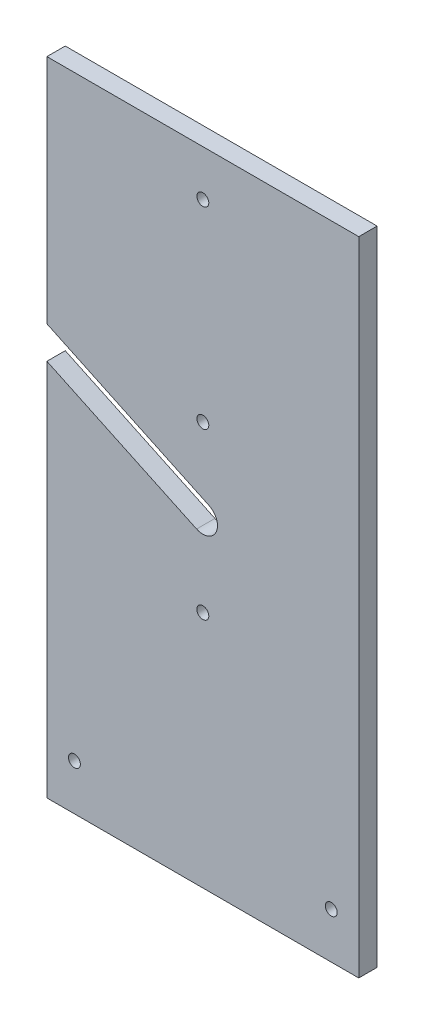
from build123d import *

# Parameters (mm, degrees)
AUFSATZ_LINEAR_AUSTRAGEN1_DEPTH  = 10
F_6_5_6_5_DURCHMESSER_BOHRUNG5_D = 6.5


with BuildPart() as part:
    # Skizze1 → Aufsatz-Linear austragen1 (new body)
    with BuildSketch(Plane.XY):
        with BuildLine():
            Line((85, 175), (-85, 175))
            Line((-85, 175), (-85, 48.841550225))
            Line((-85, 48.841550225), (3.406376291, 7.238549618))
            ThreePointArc((3.406376291, 7.238549618), (7.238549618, -3.406376291), (-3.406376291, -7.238549618))
            Line((-3.406376291, -7.238549618), (-85, 31.158449775))
            Line((-85, 31.158449775), (-85, -175))
            Line((-85, -175), (85, -175))
            Line((85, -175), (85, 175))
        make_face()
    extrude(amount=AUFSATZ_LINEAR_AUSTRAGEN1_DEPTH)

    # Ø6.5 (6.5) Durchmesser Bohrung5 (through all)
    with Locations(Plane.XY.offset(10)):
        with Locations((0, 150), (-70, -150), (70, -150), (0, 45), (0, -45)):
            Hole(F_6_5_6_5_DURCHMESSER_BOHRUNG5_D / 2)


solid = part.part
